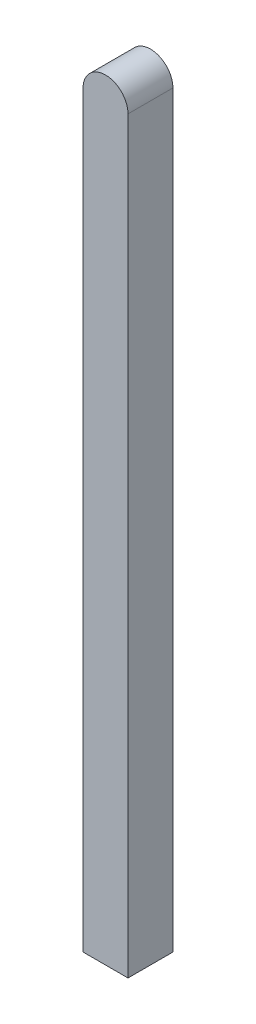
from build123d import *

# Parameters (mm, degrees)
SKETCH1_W           = 30
SKETCH1_H           = 30
BOSS_EXTRUDE1_DEPTH = 500
SKETCH2_R           = 15
BOSS_EXTRUDE2_DEPTH = 30
SKETCH4_R           = 10
CUT_EXTRUDE1_DEPTH  = 50


with BuildPart() as part:
    # Sketch1 → Boss-Extrude1 (new body)
    with BuildSketch(Plane(origin=(0, 0, 0), x_dir=(1, 0, 0), z_dir=(0, 1, 0))):
        Rectangle(SKETCH1_W, SKETCH1_H)
    extrude(amount=BOSS_EXTRUDE1_DEPTH)

    # Sketch2 → Boss-Extrude2 (add)
    with BuildSketch(Plane.XY.offset(15)):
        with Locations((0, 500)):
            Circle(SKETCH2_R)
    extrude(amount=-BOSS_EXTRUDE2_DEPTH)

    # Sketch4 → Cut-Extrude1 (cut)
    with BuildSketch(Plane.XZ):
        Circle(SKETCH4_R)
    extrude(amount=-CUT_EXTRUDE1_DEPTH, mode=Mode.SUBTRACT)


solid = part.part
